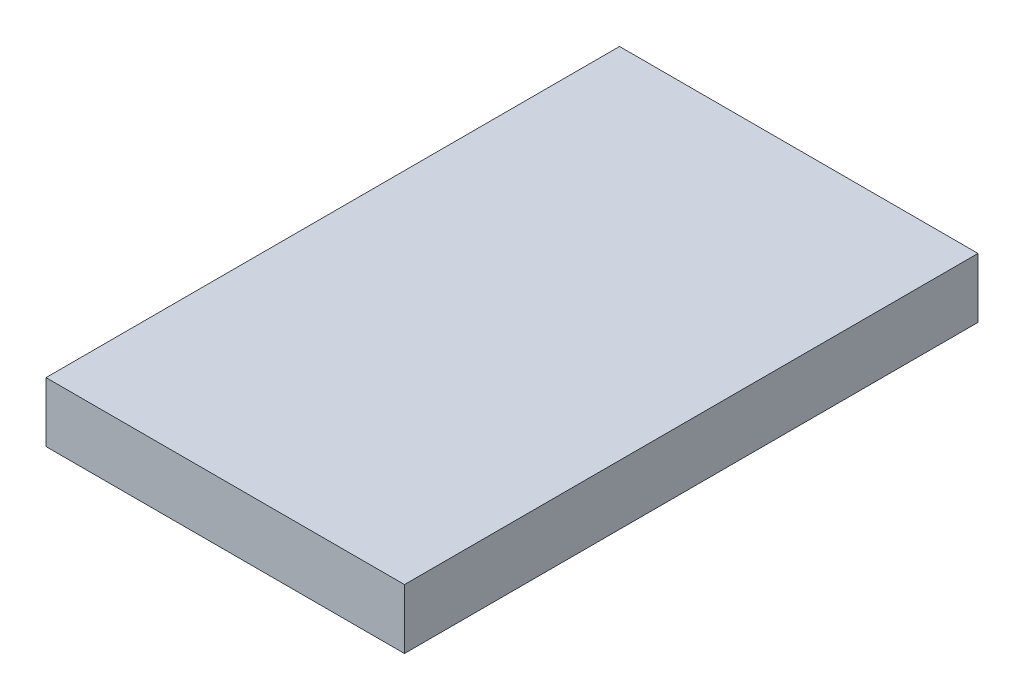
from build123d import *

# Parameters (mm, degrees)
SKETCH1_W           = 19.05
SKETCH1_H           = 30.48
BOSS_EXTRUDE1_DEPTH = 3.175


with BuildPart() as part:
    # Sketch1 → Boss-Extrude1 (new body)
    with BuildSketch(Plane(origin=(0, 0, 0), x_dir=(1, 0, 0), z_dir=(0, 1, 0))):
        Rectangle(SKETCH1_W, SKETCH1_H)
    extrude(amount=BOSS_EXTRUDE1_DEPTH)


solid = part.part
